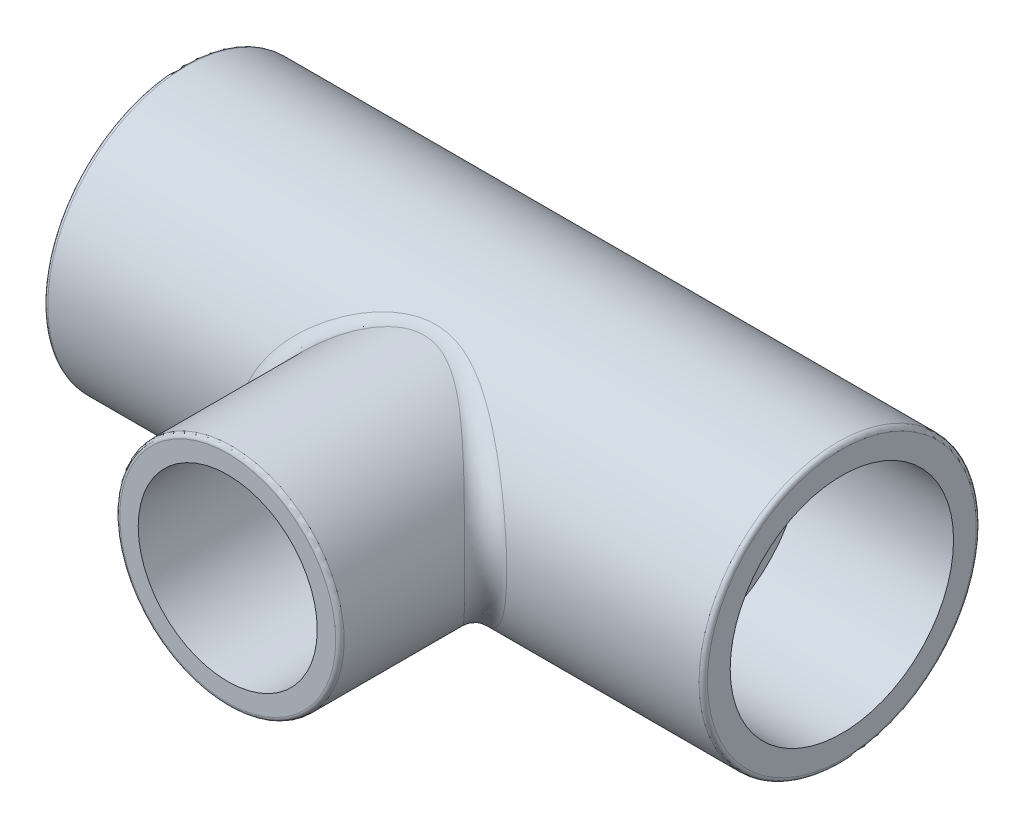
from build123d import *

# Parameters (mm, degrees)
SKETCH1_R           = 0.6565
SKETCH1_R_2         = 0.412
BOSS_EXTRUDE1_DEPTH = 3.125
SKETCH2_R           = 0.529
CUT_EXTRUDE1_DEPTH  = 0.72
SKETCH3_R           = 0.529
CUT_EXTRUDE2_DEPTH  = 0.72
SKETCH4_R           = 0.5315
SKETCH4_R_2         = 0.311
BOSS_EXTRUDE2_DEPTH = 1.3465
SKETCH5_R           = 0.412
CUT_EXTRUDE3_DEPTH  = 4.1250001
CUT_EXTRUDE4_REACH  = 4.003
SKETCH6_R           = 0.311
SKETCH8_R           = 0.424
CUT_EXTRUDE5_DEPTH  = 0.69
FILLET1_R           = 0.1
FILLET2_R           = 0.02
FILLET3_R           = 0.02
FILLET4_R           = 0.02


with BuildPart() as part:
    # Sketch1 → Boss-Extrude1 (new body)
    with BuildSketch(Plane.YZ):
        Circle(SKETCH1_R)
        Circle(SKETCH1_R_2, mode=Mode.SUBTRACT)
    extrude(amount=BOSS_EXTRUDE1_DEPTH)

    # Sketch2 → Cut-Extrude1 (cut)
    with BuildSketch(Plane(origin=(3.125, 0, 0), x_dir=(0, 0, -1), z_dir=(1, 0, 0))):
        Circle(SKETCH2_R)
    extrude(amount=-CUT_EXTRUDE1_DEPTH, mode=Mode.SUBTRACT)

    # Sketch3 → Cut-Extrude2 (cut)
    with BuildSketch(Plane.ZY):
        Circle(SKETCH3_R)
    extrude(amount=-CUT_EXTRUDE2_DEPTH, mode=Mode.SUBTRACT)

    # Sketch4 → Boss-Extrude2 (add)
    with BuildSketch(Plane(origin=(0, 0, 0), x_dir=(0, 1, 0), z_dir=(0, 0, 1))):
        with Locations((0, -1.5625)):
            Circle(SKETCH4_R)
        with Locations((0, -1.5625)):
            Circle(SKETCH4_R_2, mode=Mode.SUBTRACT)
    extrude(amount=BOSS_EXTRUDE2_DEPTH)

    # Sketch5 → Cut-Extrude3 (cut, through all)
    with BuildSketch(Plane.YZ.offset(3.125)):
        Circle(SKETCH5_R)
    extrude(amount=-CUT_EXTRUDE3_DEPTH, mode=Mode.SUBTRACT)

    # Sketch6 → Cut-Extrude4 (cut, up to next)
    with BuildSketch(Plane.XY.offset(1.3465), mode=Mode.PRIVATE) as cut_extrude4_sk1:
        with Locations((1.5625, 0)):
            Circle(SKETCH6_R)
    cut_extrude4_tool1 = extrude(cut_extrude4_sk1.sketch, amount=-CUT_EXTRUDE4_REACH, mode=Mode.PRIVATE) & part.part
    add(cut_extrude4_tool1.solids().sort_by_distance((1.5625, 0, 1.3465))[0], mode=Mode.SUBTRACT)

    # Sketch8 → Cut-Extrude5 (cut)
    with BuildSketch(Plane.XY.offset(1.3465)):
        with Locations((1.5625, 0)):
            Circle(SKETCH8_R)
    extrude(amount=-CUT_EXTRUDE5_DEPTH, mode=Mode.SUBTRACT)

    # Fillet1
    fillet1_edges = [part.edges().sort_by_distance(p)[0] for p in [
        (1.5625, -0.5315, 0.385356977),
    ]]
    fillet(fillet1_edges, radius=FILLET1_R)

    # Fillet2
    fillet2_edges = [part.edges().sort_by_distance(p)[0] for p in [
        (1.5625, -0.5315, 1.3465),
    ]]
    fillet(fillet2_edges, radius=FILLET2_R)

    # Fillet3
    fillet3_edges = [part.edges().sort_by_distance(p)[0] for p in [
        (0, -0.6565, 0),
    ]]
    fillet(fillet3_edges, radius=FILLET3_R)

    # Fillet4
    fillet4_edges = [part.edges().sort_by_distance(p)[0] for p in [
        (3.125, -0.6565, 0),
    ]]
    fillet(fillet4_edges, radius=FILLET4_R)


solid = part.part
